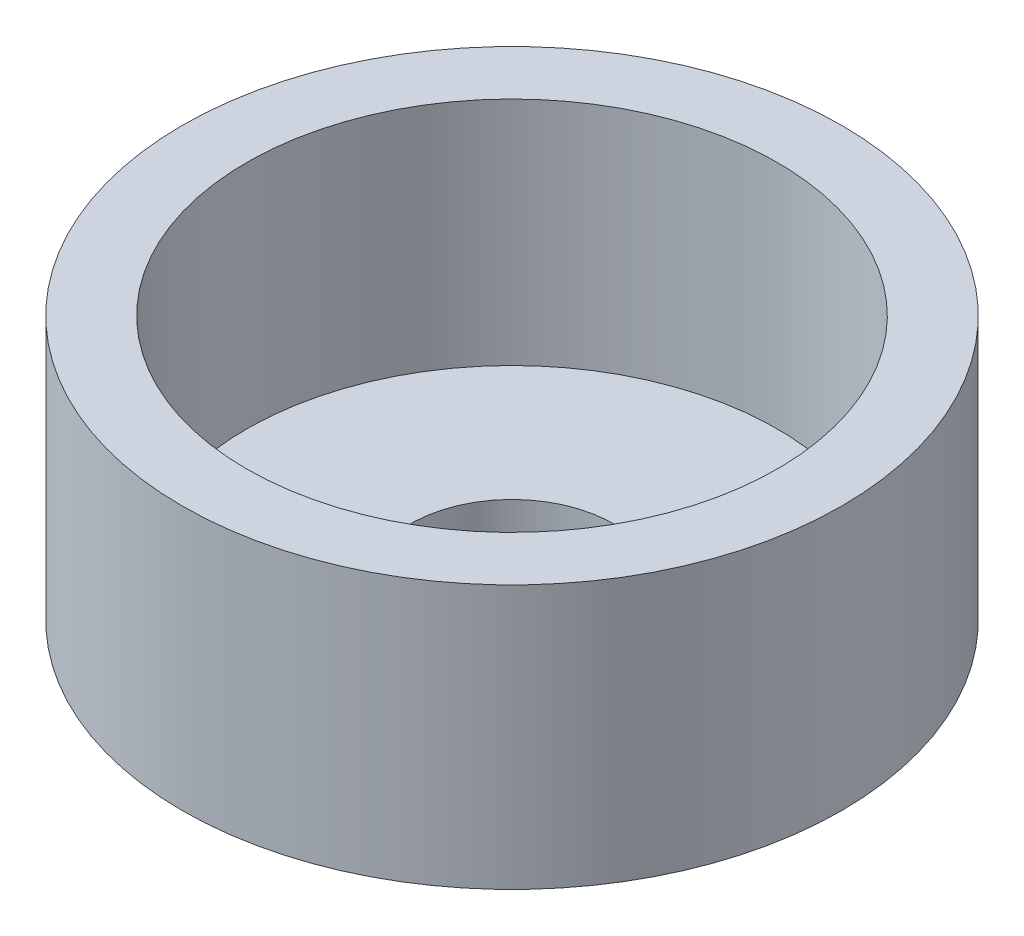
from build123d import *

# Parameters (mm, degrees)
ESQUISSE1_R        = 10
ESQUISSE1_R_2      = 8.05
ESQUISSE1_R_3      = 3.075
BOSS_EXTRU_2_DEPTH = 1
ESQUISSE2_R        = 10
ESQUISSE2_R_2      = 8.05
BOSS_EXTRU_3_DEPTH = 7


with BuildPart() as part:
    # Esquisse1 → Boss.-Extru.2 (new body)
    with BuildSketch(Plane(origin=(0, 0, 0), x_dir=(1, 0, 0), z_dir=(0, 1, 0))):
        Circle(ESQUISSE1_R)
        Circle(ESQUISSE1_R_2, mode=Mode.SUBTRACT)
        Circle(ESQUISSE1_R_2)
        Circle(ESQUISSE1_R_3, mode=Mode.SUBTRACT)
    extrude(amount=BOSS_EXTRU_2_DEPTH)

    # Esquisse2 → Boss.-Extru.3 (add)
    with BuildSketch(Plane(origin=(0, 1, 0), x_dir=(1, 0, 0), z_dir=(0, 1, 0))):
        Circle(ESQUISSE2_R)
        Circle(ESQUISSE2_R_2, mode=Mode.SUBTRACT)
    extrude(amount=BOSS_EXTRU_3_DEPTH)


solid = part.part
